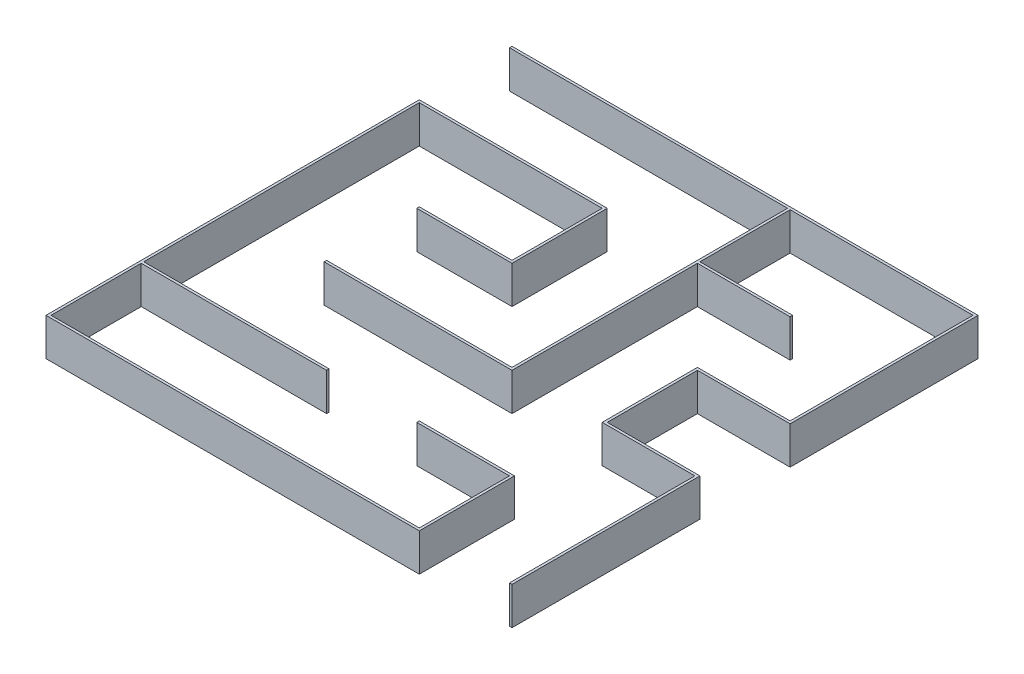
from build123d import *

# Parameters (mm, degrees)
BOSS_EXTRUDE1_DEPTH   = 150
BOSS_EXTRUDE1_2_DEPTH = 150


with BuildPart() as part:
    # Sketch1 → Boss-Extrude1 (new body)
    with BuildSketch(Plane(origin=(0, 0, 0), x_dir=(1, 0, 0), z_dir=(0, 1, 0))):
        Polygon((0, 1860), (-1860, 1860), (-1860, 1850), (-750, 1850), (-750, 750), (-1490, 750), (-1490, 740), (-740, 740), (-740, 1480), (-370, 1480), (-370, 1490), (-740, 1490), (-740, 1850), (-10, 1850), (-10, 1120), (-380, 1120), (-380, 740), (-10, 740), (-10, 0), (0, 0), (0, 750), (-370, 750), (-370, 1110), (0, 1110), align=None)
    extrude(amount=BOSS_EXTRUDE1_DEPTH)


with BuildPart() as body_2:
    # Sketch1 → Boss-Extrude1 2 (new body)
    with BuildSketch(Plane(origin=(0, 0, 0), x_dir=(1, 0, 0), z_dir=(0, 1, 0))):
        Polygon((-750, 370), (-380, 370), (-380, 10), (-1850, 10), (-1850, 370), (-1110, 370), (-1110, 380), (-1850, 380), (-1850, 1480), (-1120, 1480), (-1120, 1120), (-1490, 1120), (-1490, 1110), (-1110, 1110), (-1110, 1490), (-1860, 1490), (-1860, 0), (-370, 0), (-370, 380), (-750, 380), align=None)
    extrude(amount=BOSS_EXTRUDE1_2_DEPTH)


solid = Compound([part.part, body_2.part])
